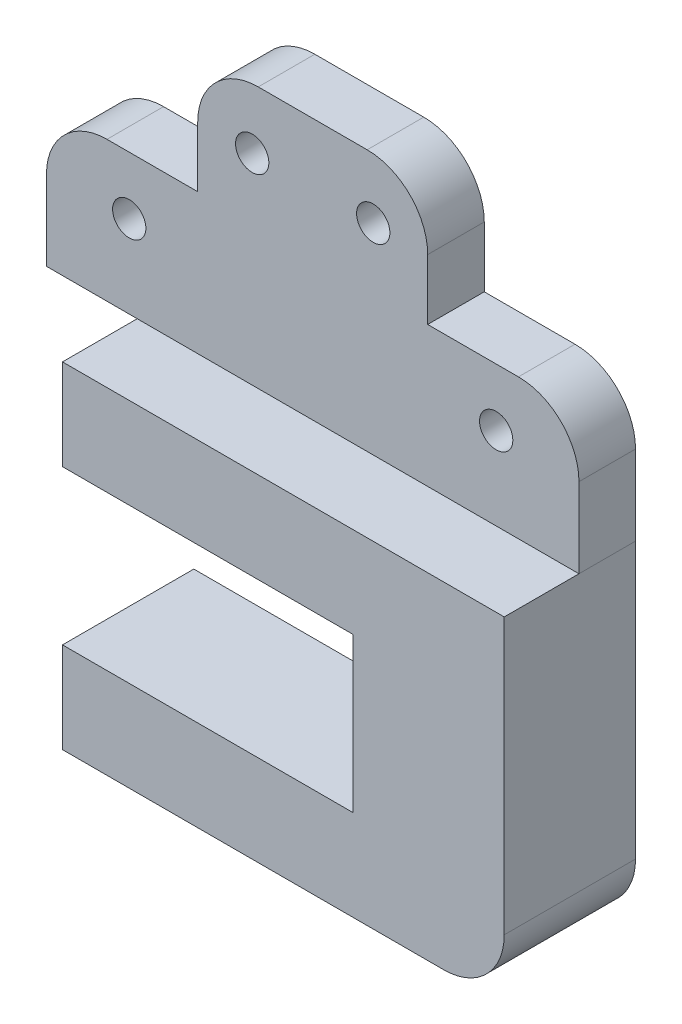
from build123d import *

# Parameters (mm, degrees)
SKETCH1_R           = 2.75
BOSS_EXTRUDE1_DEPTH = 9.35
BOSS_EXTRUDE2_DEPTH = 21.7
SKETCH3_R           = 1.75
CUT_EXTRUDE2_DEPTH  = 15
FILLET1_R           = 10
FILLET2_R           = 10


with BuildPart() as part:
    # Sketch1 → Boss-Extrude1 (new body)
    with BuildSketch(Plane.XY):
        Polygon((-44, 0), (-44, 23.18), (-19, 23.18), (-19, 43.18), (19, 43.18), (19, 23.18), (44, 23.18), (44, 0), align=None)
        with Locations((10, 33.18)):
            Circle(SKETCH1_R, mode=Mode.SUBTRACT)
        with Locations((30.32, 13.65)):
            Circle(SKETCH1_R, mode=Mode.SUBTRACT)
        with Locations((-30.32, 13.65)):
            Circle(SKETCH1_R, mode=Mode.SUBTRACT)
        with Locations((-10, 33.18)):
            Circle(SKETCH1_R, mode=Mode.SUBTRACT)
    extrude(amount=BOSS_EXTRUDE1_DEPTH)

    # Fillet1
    fillet1_edges = [part.edges().sort_by_distance(p)[0] for p in [
        (-44, 23.18, 4.675),
        (-19, 43.18, 4.675),
        (19, 43.18, 4.675),
        (44, 23.18, 4.675),
    ]]
    fillet(fillet1_edges, radius=FILLET1_R)


with BuildPart() as body_2:
    # Sketch2 → Boss-Extrude2 (new body)
    with BuildSketch(Plane(origin=(0, 0, 0), x_dir=(-1, 0, 0), z_dir=(0, 0, -1))):
        Polygon((-44, 0), (-44, -55.5), (29, -55.5), (29, -40.5), (-19, -40.5), (-19, -15), (29, -15), (29, 0), align=None)
    extrude(amount=-BOSS_EXTRUDE2_DEPTH)

    # Sketch3 → Cut-Extrude2 (cut)
    with BuildSketch(Plane.ZY.offset(29)):
        with Locations((5.145, -7.5)):
            Circle(SKETCH3_R)
        with Locations((16.555, -7.5)):
            Circle(SKETCH3_R)
        with Locations((5.145, -48)):
            Circle(SKETCH3_R)
        with Locations((16.555, -48)):
            Circle(SKETCH3_R)
    extrude(amount=-CUT_EXTRUDE2_DEPTH, mode=Mode.SUBTRACT)

    # Fillet2
    fillet2_edges = [body_2.edges().sort_by_distance(p)[0] for p in [
        (44, -55.5, 10.85),
    ]]
    fillet(fillet2_edges, radius=FILLET2_R)


solid = Compound([part.part, body_2.part])
